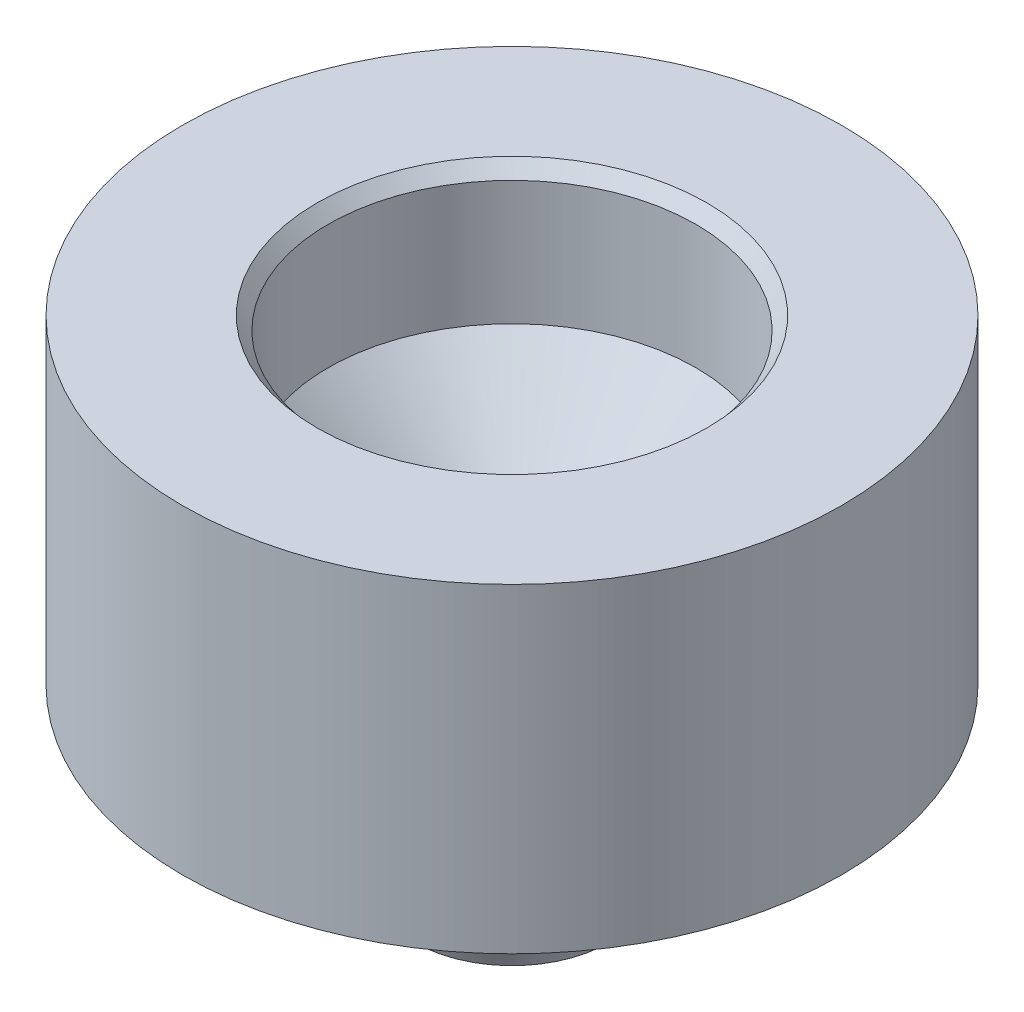
from build123d import *

# Parameters (mm, degrees)
CHAMFER1_SIZE  = 3
CHAMFER2_SIZE  = 0.2
CHAMFER2_SIZE2 = 0.549495484
CHAMFER3_SIZE  = 0.4
CHAMFER3_SIZE2 = 0.476701437


with BuildPart() as part:
    # Sketch1 → Revolve1 (revolve)
    with BuildSketch(Plane.XY):
        Polygon((0, 0), (3.75, 0), (3.75, 6.35), (12, 6.35), (12, 18), (6.7, 18), (6.7, 10), (0, 10), align=None)
    revolve(axis=Axis((0, 10, 0), (0, -1, 0)))

    # Chamfer1
    chamfer1_edges = [part.edges().sort_by_distance(p)[0] for p in [
        (-6.7, 10, 0),
    ]]
    chamfer(chamfer1_edges, length=CHAMFER1_SIZE)

    # Chamfer2
    chamfer2_edges = [part.edges().sort_by_distance(p)[0] for p in [
        (-3.75, 0, 0),
    ]]
    chamfer2_side = [part.faces().sort_by_distance(p)[0] for p in [
        (0, 0, 0),
    ]]
    chamfer(chamfer2_edges, length=CHAMFER2_SIZE, length2=CHAMFER2_SIZE2, reference=chamfer2_side[0])

    # Chamfer3
    chamfer3_edges = [part.edges().sort_by_distance(p)[0] for p in [
        (-6.7, 18, 0),
    ]]
    chamfer3_side = [part.faces().sort_by_distance(p)[0] for p in [
        (-11.660588745, 18, 0),
    ]]
    chamfer(chamfer3_edges, length=CHAMFER3_SIZE, length2=CHAMFER3_SIZE2, reference=chamfer3_side[0])


solid = part.part
